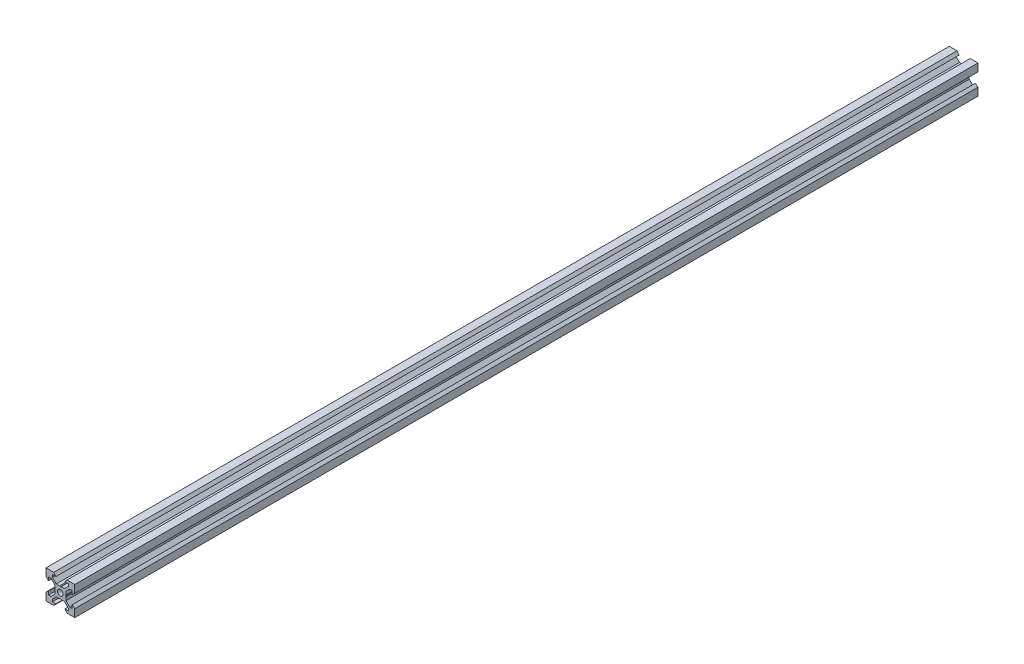
from build123d import *

# Parameters (mm, degrees)
SKETCH1_R           = 2
BOSS_EXTRUDE1_DEPTH = 314.19


with BuildPart() as part:
    # Sketch1 → Boss-Extrude1 (new body, symmetric)
    with BuildSketch(Plane.XY):
        Polygon((10, 10), (10, 4.610379336), (8.2, 3.1), (8.2, 5.5), (6.560660172, 5.5), (3.9, 2.839339828), (3.9, 0.519615242), (3.6, 0), (3.9, -0.519615242), (3.9, -2.839339828), (6.560660172, -5.5), (8.2, -5.5), (8.2, -3.1), (10, -4.610379336), (10, -10), (4.610379336, -10), (3.1, -8.2), (5.5, -8.2), (5.5, -6.560660172), (2.839339828, -3.9), (0.519615242, -3.9), (0, -3.6), (-0.519615242, -3.9), (-2.839339828, -3.9), (-5.5, -6.560660172), (-5.5, -8.2), (-3.1, -8.2), (-4.610379336, -10), (-10, -10), (-10, -4.610379336), (-8.2, -3.1), (-8.2, -5.5), (-6.560660172, -5.5), (-3.9, -2.839339828), (-3.9, -0.519615242), (-3.6, 0), (-3.9, 0.519615242), (-3.9, 2.839339828), (-6.560660172, 5.5), (-8.2, 5.5), (-8.2, 3.1), (-10, 4.610379336), (-10, 10), (-4.610379336, 10), (-3.1, 8.2), (-5.5, 8.2), (-5.5, 6.560660172), (-2.839339828, 3.9), (-0.519615242, 3.9), (0, 3.6), (0.519615242, 3.9), (2.839339828, 3.9), (5.5, 6.560660172), (5.5, 8.2), (3.1, 8.2), (4.610379336, 10), align=None)
        Circle(SKETCH1_R, mode=Mode.SUBTRACT)
    extrude(amount=BOSS_EXTRUDE1_DEPTH, both=True)


solid = part.part
